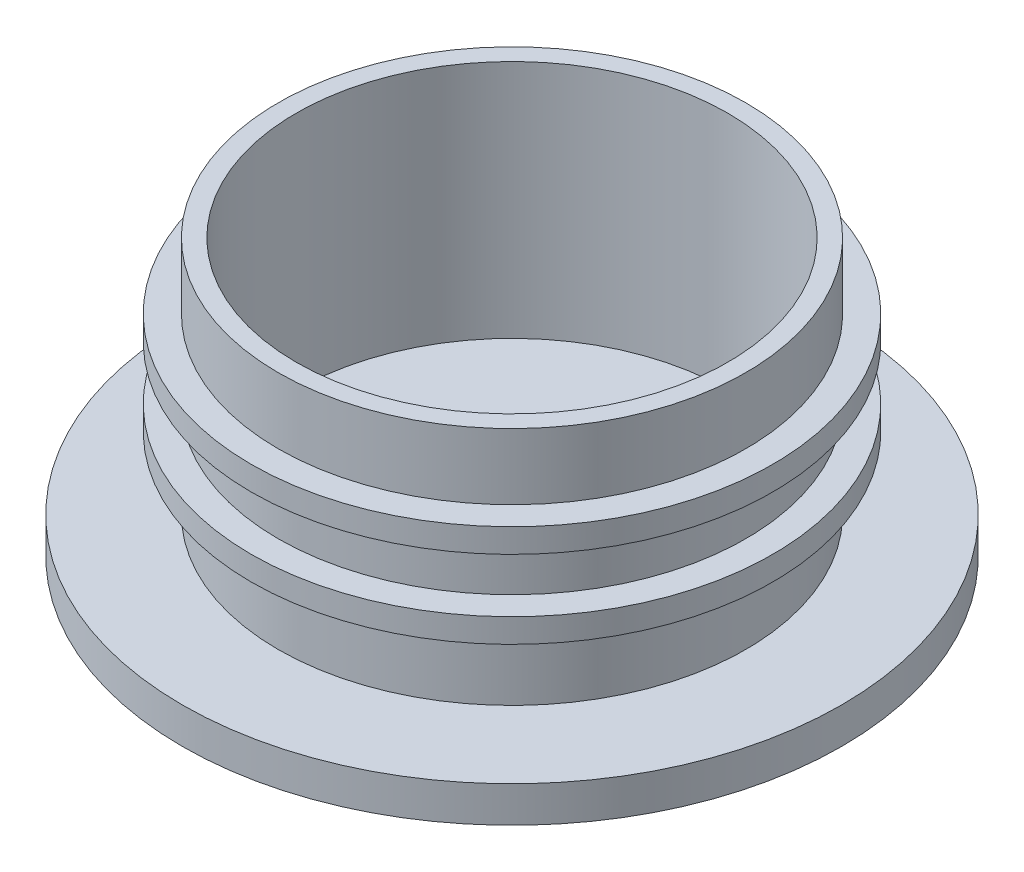
from build123d import *

# Parameters (mm, degrees)
SKETCH_1_R          = 19.5
SKETCH_1_R_2        = 18
EXTRUDE_1_DEPTH     = 20
SKETCH_3_R          = 27.5
EXTRUDE_2_DEPTH     = 3
SKETCH_4_R          = 21.75
EXTRUDE_3_DEPTH     = 2
EXTRUDE_START       = 1
SKETCH_8_R          = 21.75
EXTRUDE_4_DEPTH     = 2
SKETCH_6_R          = 18
CUT_EXTRUDE_1_DEPTH = 35


with BuildPart() as part:
    # 草圖1 → 填料-伸長1 (new body)
    with BuildSketch(Plane(origin=(0, 0, 0), x_dir=(1, 0, 0), z_dir=(0, 1, 0))):
        Circle(SKETCH_1_R)
        Circle(SKETCH_1_R_2, mode=Mode.SUBTRACT)
    extrude(amount=EXTRUDE_1_DEPTH)

    # 草圖3 → 填料-伸長2 (add)
    with BuildSketch(Plane.XZ):
        Circle(SKETCH_3_R)
    extrude(amount=EXTRUDE_2_DEPTH)

    # 草圖4 → 填料-伸長3 (add)
    with BuildSketch(Plane(origin=(0, 8, 0), x_dir=(1, 0, 0), z_dir=(0, 1, 0))):
        Circle(SKETCH_4_R)
    extrude(amount=-EXTRUDE_3_DEPTH)

    # 草圖8 → 填料-伸長4 (add)
    with BuildSketch(Plane(origin=(0, 11.5, 0), x_dir=(1, 0, 0), z_dir=(0, 1, 0)).offset(EXTRUDE_START)):
        Circle(SKETCH_8_R)
    extrude(amount=EXTRUDE_4_DEPTH)

    # 草圖6 → 除料-伸長1 (cut)
    with BuildSketch(Plane(origin=(0, 0, 0), x_dir=(1, 0, 0), z_dir=(0, 1, 0))):
        Circle(SKETCH_6_R)
    extrude(amount=CUT_EXTRUDE_1_DEPTH, mode=Mode.SUBTRACT)


solid = part.part
